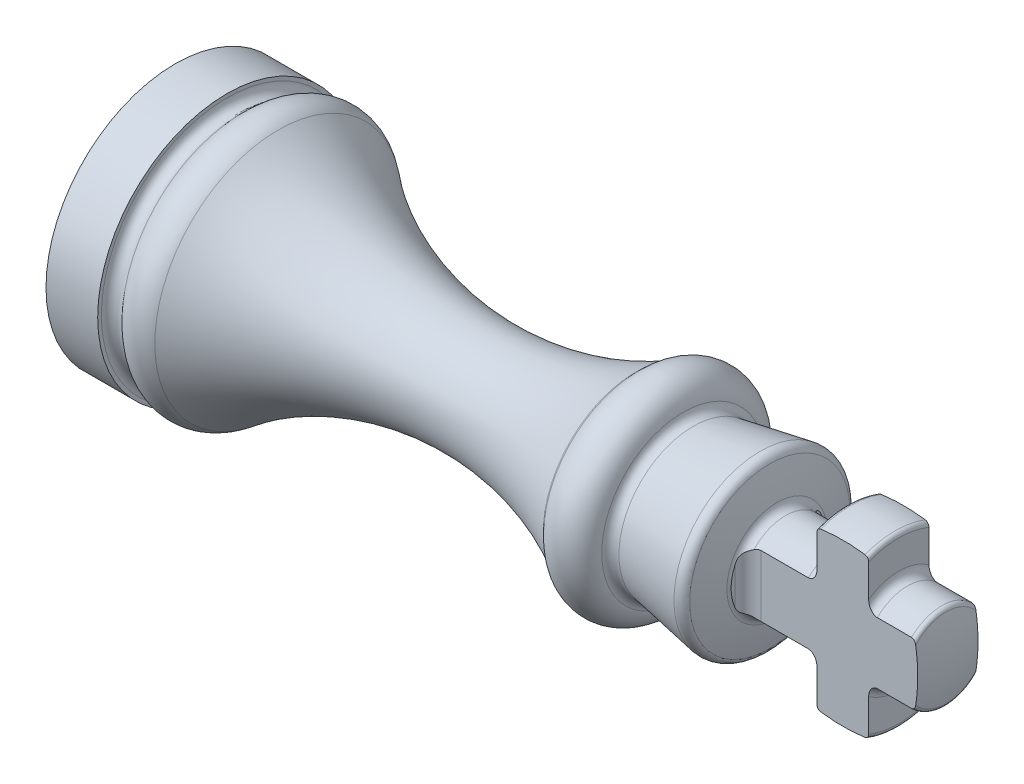
from build123d import *

# Parameters (mm, degrees)
CUT_EXTRUDE1_DEPTH      = 47.233105055
CUT_EXTRUDE1_DEPTH_BACK = 47.233105055


with BuildPart() as part:
    # Sketch1 → Revolve1 (revolve)
    with BuildSketch(Plane.XY):
        with BuildLine():
            Line((0, 0), (0, -7.5))
            Line((0, -7.5), (3, -7.5))
            Line((3, -7.5), (3, -7.285575219))
            ThreePointArc((3, -7.285575219), (3.328989928, -6.815728909), (3.883022222, -6.964181415))
            ThreePointArc((3.883022222, -6.964181415), (4.890464481, -7.493299209), (5.979413508, -7.163003036))
            ThreePointArc((5.979413508, -7.163003036), (16.066763392, -3.070528449), (26.71156181, -5.348958295))
            ThreePointArc((26.71156181, -5.348958295), (26.786499921, -5.400216722), (26.850933335, -5.464181415))
            ThreePointArc((26.850933335, -5.464181415), (28.405194999, -5.944235789), (29.482914654, -4.725752361))
            ThreePointArc((29.482914654, -4.725752361), (29.685647378, -4.39481886), (30.064043628, -4.308599271))
            Line((30.064043628, -4.308599271), (33.942092256, -4.992403877))
            ThreePointArc((33.942092256, -4.992403877), (34.290622077, -4.926040033), (34.507380763, -4.64516129))
            ThreePointArc((34.507380763, -4.64516129), (34.742859832, -3.783027658), (34.929834027, -2.909090909))
            ThreePointArc((34.929834027, -2.909090909), (35.101699036, -2.615646943), (35.42150011, -2.5))
            Line((35.42150011, -2.5), (38.5, -2.5))
            ThreePointArc((38.5, -2.5), (38.853553391, -2.646446609), (39, -3))
            Line((39, -3), (39, -4.669539803))
            ThreePointArc((39, -4.669539803), (39.062233096, -4.834596126), (39.217948718, -4.917476721))
            ThreePointArc((39.217948718, -4.917476721), (40.5, -5), (41.782051282, -4.917476721))
            ThreePointArc((41.782051282, -4.917476721), (41.937766904, -4.834596126), (42, -4.669539803))
            Line((42, -4.669539803), (42, -3))
            ThreePointArc((42, -3), (42.146446609, -2.646446609), (42.5, -2.5))
            Line((42.5, -2.5), (44.486832981, -2.5))
            ThreePointArc((44.486832981, -2.5), (44.641876399, -2.446116135), (44.730085108, -2.307692308))
            ThreePointArc((44.730085108, -2.307692308), (44.932292059, -1.161711866), (45, 0))
            Line((45, 0), (0, 0))
        make_face()
    revolve(axis=Axis((0, 0, 0), (-1, 0, 0)))

    # Sketch2 → Cut-Extrude1 (cut, two sides: drawn at the far end of the back side and taken through both)
    with BuildSketch(Plane(origin=(0, 0, 0), x_dir=(1, 0, 0), z_dir=(0, 1, 0)).offset(-CUT_EXTRUDE1_DEPTH_BACK)):
        with BuildLine():
            Line((45, -6), (35, -6))
            Line((35, -6), (35, -2.512))
            ThreePointArc((35, -2.512), (35.223184633, -1.973184633), (35.762, -1.75))
            Line((35.762, -1.75), (45, -1.75))
            Line((45, -1.75), (45, -6))
        make_face()
        with BuildLine():
            Line((35, 6), (35, 2.512))
            ThreePointArc((35, 2.512), (35.223184633, 1.973184633), (35.762, 1.75))
            Line((35.762, 1.75), (45, 1.75))
            Line((45, 1.75), (45, 6))
            Line((45, 6), (35, 6))
        make_face()
    extrude(amount=CUT_EXTRUDE1_DEPTH + CUT_EXTRUDE1_DEPTH_BACK, mode=Mode.SUBTRACT)


solid = part.part
